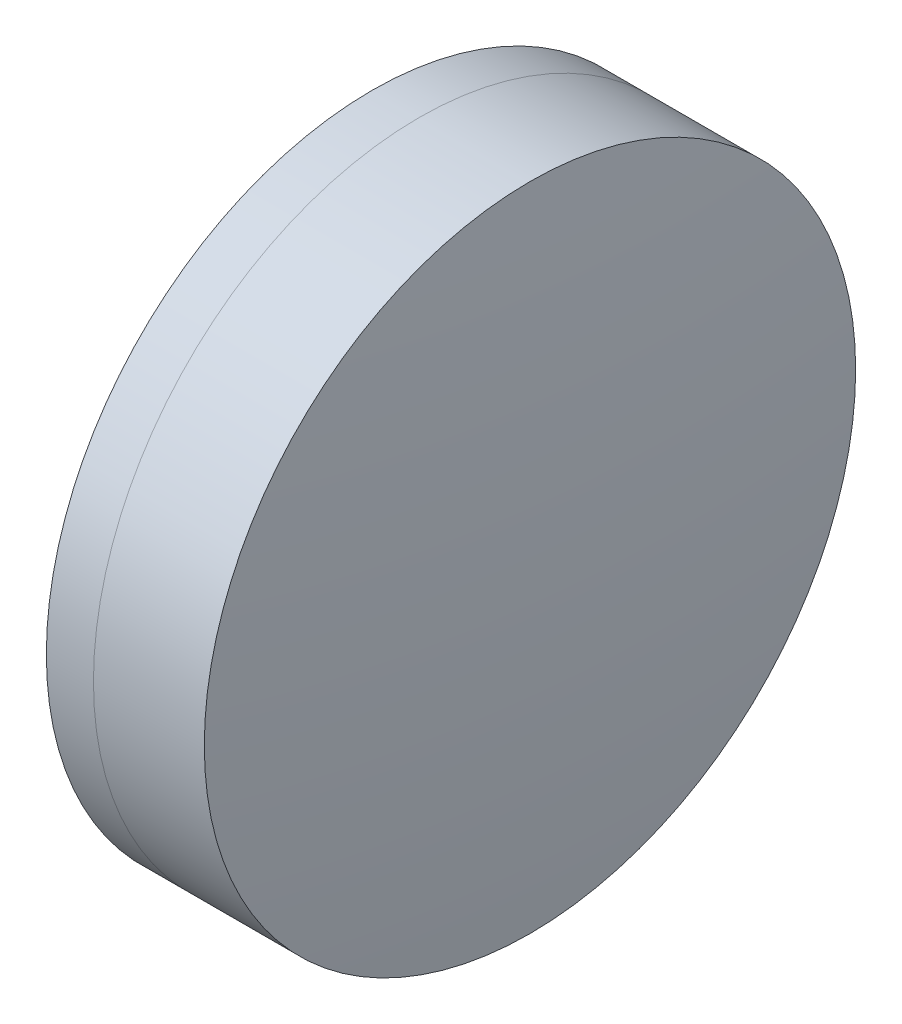
from build123d import *


with BuildPart() as part:
    # 草图1 one side → 旋转1 (revolve)
    with BuildSketch(Plane(origin=(0, 0, 0), x_dir=(1, 0, 0), z_dir=(0, 1, 0)), mode=Mode.PRIVATE) as revolve_1_sk:
        with BuildLine():
            ThreePointArc((286.525605096, 12.7), (284.659057576, 6.471535833), (284.028986555, 0))
            Line((284.028986555, 0), (291.528986555, 0))
            ThreePointArc((291.528986555, 0), (290.725377139, 6.544423678), (288.362296627, 12.7))
            Line((288.362296627, 12.7), (286.525605096, 12.7))
        make_face()
    revolve(revolve_1_sk.sketch.rotate(Axis((124.523309526, 0, 0), (1, 0, 0)), 180), axis=Axis((124.523309526, 0, 0), (1, 0, 0)))  # turned: the seam where the file's is


with BuildPart() as body_2:
    # 草图2 one side → 旋转3 (revolve)
    with BuildSketch(Plane(origin=(0, 0, 0), x_dir=(1, 0, 0), z_dir=(0, 1, 0)), mode=Mode.PRIVATE) as revolve_3_sk:
        with BuildLine():
            Line((292.685258906, 12.7), (288.362296627, 12.7))
            ThreePointArc((288.362296627, 12.7), (290.725377139, 6.544423678), (291.528986555, 0))
            Line((291.528986555, 0), (293.328986555, 0))
            ThreePointArc((293.328986555, 0), (293.167951409, 6.358151958), (292.685258906, 12.7))
        make_face()
    revolve(revolve_3_sk.sketch.rotate(Axis((-0.551919993, 0, 0), (1, 0, 0)), 180), axis=Axis((-0.551919993, 0, 0), (1, 0, 0)))  # turned: the seam where the file's is


solid = Compound([part.part, body_2.part])
